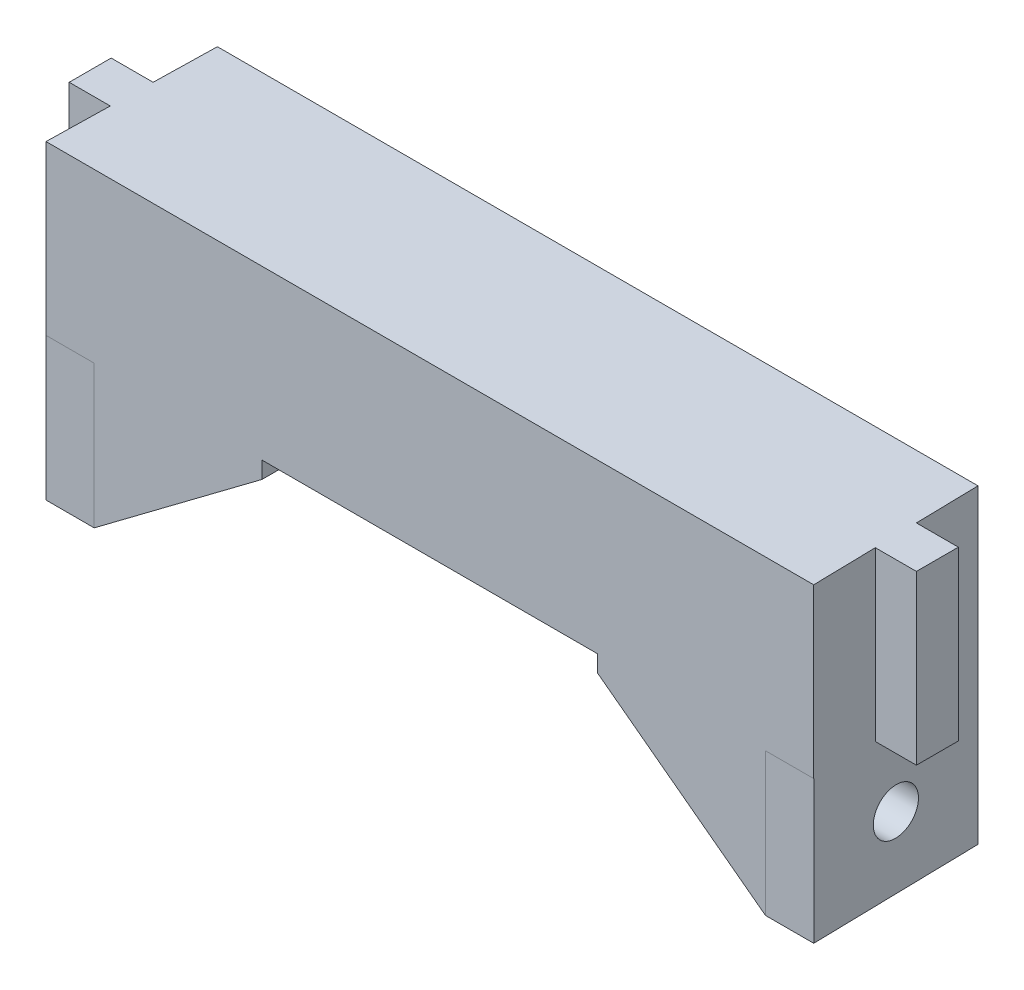
from build123d import *

# Parameters (mm, degrees)
BOSS_EXTRUDE1_DEPTH = 20
SKETCH2_W           = 5
SKETCH2_H           = 5
BOSS_EXTRUDE2_DEPTH = 20
SKETCH4_W           = 20
SKETCH4_H           = 17
SKETCH3_W           = 19.999551015
SKETCH3_H           = 17
SKETCH6_W           = 20
SKETCH6_H           = 17
SKETCH5_W           = 20
SKETCH5_H           = 2
SKETCH7_R           = 2.75
CUT_EXTRUDE1_DEPTH  = 11.47488838
SKETCH8_R           = 6.5
CUT_EXTRUDE2_DEPTH  = 30


with BuildPart() as part:
    # Sketch1 → Boss-Extrude1 (new body)
    with BuildSketch(Plane(origin=(0, 0, 0), x_dir=(1, 0, 0), z_dir=(0, 1, 0))):
        Polygon((-45.74, 0), (-45.315821408, 20), (45.315821408, 20), (45.74, 0), align=None)
    extrude(amount=BOSS_EXTRUDE1_DEPTH)

    # Sketch2 → Boss-Extrude2 (add)
    with BuildSketch(Plane(origin=(0, 20, 0), x_dir=(1, 0, 0), z_dir=(0, 1, 0))):
        with Locations((47.97488838, 10)):
            Rectangle(SKETCH2_W, SKETCH2_H)
        with Locations((-47.97488838, 10)):
            Rectangle(SKETCH2_W, SKETCH2_H)
    extrude(amount=-BOSS_EXTRUDE2_DEPTH)

    # Sketch4 → Loft1 section 0
    with BuildSketch(Plane(origin=(-40, 0, 0), x_dir=(0, 0, -1), z_dir=(1, 0, 0))):
        with Locations((10, -8.5)):
            Rectangle(SKETCH4_W, SKETCH4_H)
    # Sketch3 → Loft1 section 1
    with BuildSketch(Plane(origin=(-45.719434544, 0, -0.969660269), x_dir=(-0.021204161, 0, 0.999775167), z_dir=(-0.999775167, 0, -0.021204161))):
        with Locations((-9.034843843, -8.5)):
            Rectangle(SKETCH3_W, SKETCH3_H)
    loft1 = loft()

    # Sketch6 → Loft3 section 0
    with BuildSketch(Plane(origin=(-40, 0, 0), x_dir=(0, 0, -1), z_dir=(1, 0, 0))):
        with Locations((10, -8.5)):
            Rectangle(SKETCH6_W, SKETCH6_H)
    # Sketch5 → Loft3 section 1
    with BuildSketch(Plane(origin=(-20, 0, 0), x_dir=(0, 0, -1), z_dir=(1, 0, 0))):
        with Locations((10, -1)):
            Rectangle(SKETCH5_W, SKETCH5_H)
    loft3 = loft()

    # Sketch7 → Cut-Extrude1 (cut, through all)
    with BuildSketch(Plane(origin=(-40, 0, 0), x_dir=(0, 0, -1), z_dir=(1, 0, 0))):
        with Locations((10, -8.5)):
            Circle(SKETCH7_R)
    cut_extrude1 = extrude(amount=-CUT_EXTRUDE1_DEPTH, mode=Mode.SUBTRACT)

    # Sketch8 → Cut-Extrude2 (cut)
    with BuildSketch(Plane(origin=(-40, 0, 0), x_dir=(0, 0, -1), z_dir=(1, 0, 0))):
        with Locations((10, -8.5)):
            Circle(SKETCH8_R)
    cut_extrude2 = extrude(amount=CUT_EXTRUDE2_DEPTH, mode=Mode.SUBTRACT)

    # Mirror1: Loft1, Loft3, Cut-Extrude1, Cut-Extrude2 across plane
    add(loft1.mirror(Plane(origin=(0, 0, 0), x_dir=(0, 0, 1), z_dir=(1, 0, 0))))
    add(loft3.mirror(Plane(origin=(0, 0, 0), x_dir=(0, 0, 1), z_dir=(1, 0, 0))))
    add(cut_extrude1.mirror(Plane(origin=(0, 0, 0), x_dir=(0, 0, 1), z_dir=(1, 0, 0))), mode=Mode.SUBTRACT)
    add(cut_extrude2.mirror(Plane(origin=(0, 0, 0), x_dir=(0, 0, 1), z_dir=(1, 0, 0))), mode=Mode.SUBTRACT)


solid = part.part
